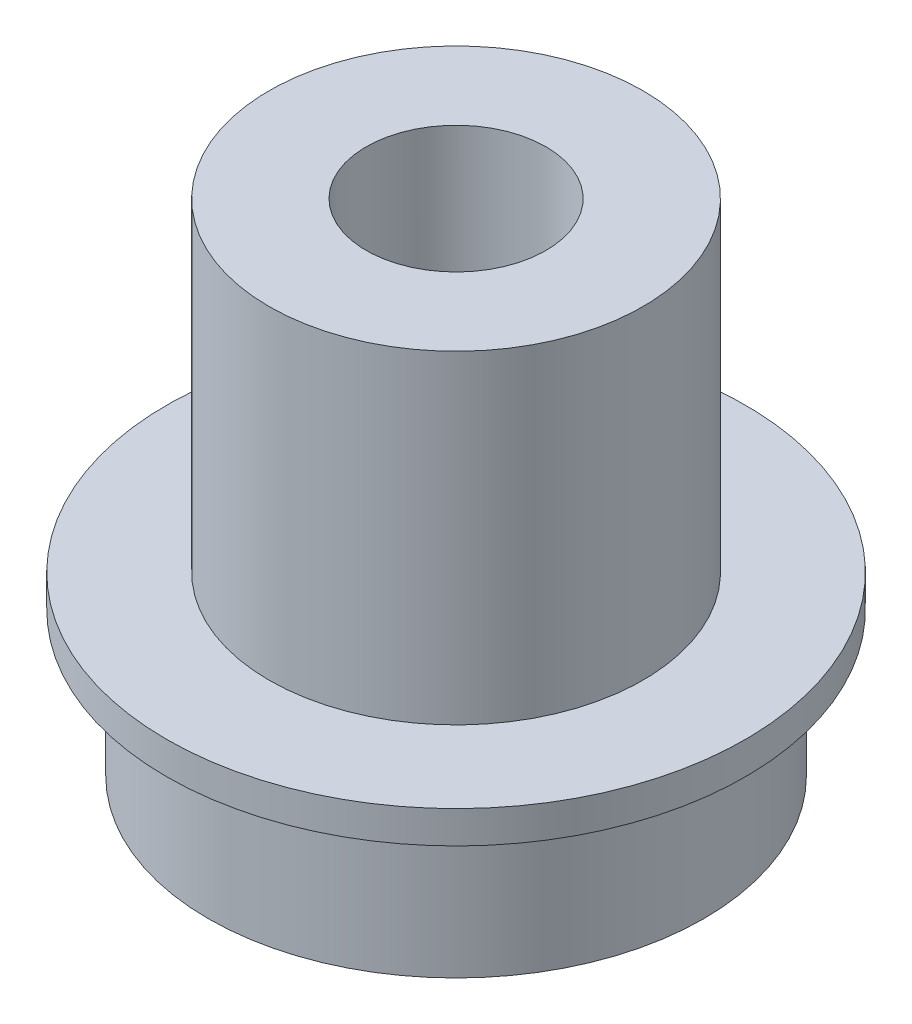
from build123d import *

# Parameters (mm, degrees)
SKETCH1_R           = 8.7503
SKETCH1_R_2         = 3.175
BOSS_EXTRUDE1_DEPTH = 5.08
SKETCH2_R           = 10.2235
SKETCH2_R_2         = 3.175
BOSS_EXTRUDE2_DEPTH = 1.143
SKETCH3_R           = 6.604
BOSS_EXTRUDE3_DEPTH = 11.43
SKETCH4_R           = 3.175
CUT_EXTRUDE1_DEPTH  = 12.43


with BuildPart() as part:
    # Sketch1 → Boss-Extrude1 (new body)
    with BuildSketch(Plane(origin=(0, 0, 0), x_dir=(1, 0, 0), z_dir=(0, 1, 0))):
        Circle(SKETCH1_R)
        Circle(SKETCH1_R_2, mode=Mode.SUBTRACT)
    extrude(amount=BOSS_EXTRUDE1_DEPTH)

    # Sketch2 → Boss-Extrude2 (add)
    with BuildSketch(Plane(origin=(0, 5.08, 0), x_dir=(1, 0, 0), z_dir=(0, 1, 0))):
        Circle(SKETCH2_R)
        Circle(SKETCH2_R_2, mode=Mode.SUBTRACT)
    extrude(amount=BOSS_EXTRUDE2_DEPTH)

    # Sketch3 → Boss-Extrude3 (add)
    with BuildSketch(Plane(origin=(0, 6.223, 0), x_dir=(1, 0, 0), z_dir=(0, 1, 0))):
        Circle(SKETCH3_R)
    extrude(amount=BOSS_EXTRUDE3_DEPTH)

    # Sketch4 → Cut-Extrude1 (cut, through all)
    with BuildSketch(Plane.XZ.offset(-6.223)):
        Circle(SKETCH4_R)
    extrude(amount=-CUT_EXTRUDE1_DEPTH, mode=Mode.SUBTRACT)


solid = part.part
